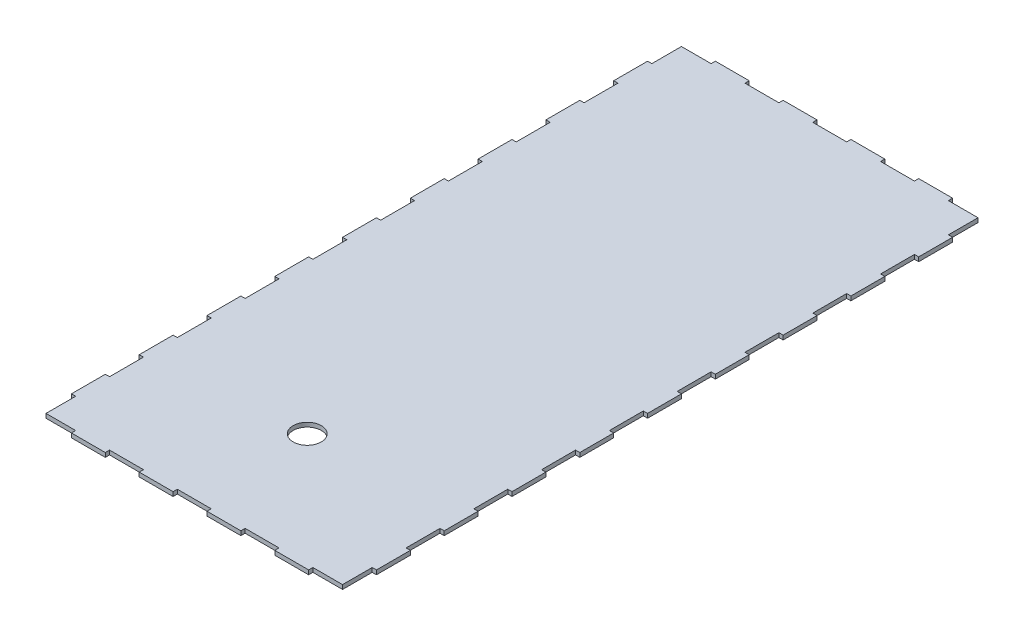
from build123d import *

# Parameters (mm, degrees)
SKETCH1_W           = 210
SKETCH1_H           = 450
SKETCH1_R           = 10
BOSS_EXTRUDE1_DEPTH = 3
SKETCH3_W           = 3
SKETCH3_H           = 24
BOSS_EXTRUDE3_DEPTH = 3
SKETCH2_W           = 24
SKETCH2_H           = 3
BOSS_EXTRUDE4_DEPTH = 3


with BuildPart() as part:
    # Sketch1 → Boss-Extrude1 (new body)
    with BuildSketch(Plane(origin=(0, 0, 0), x_dir=(1, 0, 0), z_dir=(0, 1, 0))):
        Rectangle(SKETCH1_W, SKETCH1_H)
        with Locations((0, -145)):
            Circle(SKETCH1_R, mode=Mode.SUBTRACT)
    extrude(amount=BOSS_EXTRUDE1_DEPTH)

    # Sketch3 → Boss-Extrude3 (add)
    with BuildSketch(Plane(origin=(0, 3, 0), x_dir=(1, 0, 0), z_dir=(0, 1, 0))):
        with Locations((-106.5, 192)):
            Rectangle(SKETCH3_W, SKETCH3_H)
        with Locations((106.5, 192)):
            Rectangle(SKETCH3_W, SKETCH3_H)
        with Locations((106.5, 144)):
            Rectangle(SKETCH3_W, SKETCH3_H)
        with Locations((106.5, 96)):
            Rectangle(SKETCH3_W, SKETCH3_H)
        with Locations((106.5, 48)):
            Rectangle(SKETCH3_W, SKETCH3_H)
        with Locations((106.5, 0)):
            Rectangle(SKETCH3_W, SKETCH3_H)
        with Locations((106.5, -48)):
            Rectangle(SKETCH3_W, SKETCH3_H)
        with Locations((106.5, -96)):
            Rectangle(SKETCH3_W, SKETCH3_H)
        with Locations((106.5, -144)):
            Rectangle(SKETCH3_W, SKETCH3_H)
        with Locations((106.5, -192)):
            Rectangle(SKETCH3_W, SKETCH3_H)
        with Locations((-106.5, 144)):
            Rectangle(SKETCH3_W, SKETCH3_H)
        with Locations((-106.5, 96)):
            Rectangle(SKETCH3_W, SKETCH3_H)
        with Locations((-106.5, 48)):
            Rectangle(SKETCH3_W, SKETCH3_H)
        with Locations((-106.5, 0)):
            Rectangle(SKETCH3_W, SKETCH3_H)
        with Locations((-106.5, -48)):
            Rectangle(SKETCH3_W, SKETCH3_H)
        with Locations((-106.5, -96)):
            Rectangle(SKETCH3_W, SKETCH3_H)
        with Locations((-106.5, -144)):
            Rectangle(SKETCH3_W, SKETCH3_H)
        with Locations((-106.5, -192)):
            Rectangle(SKETCH3_W, SKETCH3_H)
    extrude(amount=-BOSS_EXTRUDE3_DEPTH)

    # Sketch2 → Boss-Extrude4 (add)
    with BuildSketch(Plane(origin=(0, 3, 0), x_dir=(1, 0, 0), z_dir=(0, 1, 0))):
        with Locations((-72, 226.5)):
            Rectangle(SKETCH2_W, SKETCH2_H)
        with Locations((-24, 226.5)):
            Rectangle(SKETCH2_W, SKETCH2_H)
        with Locations((24, 226.5)):
            Rectangle(SKETCH2_W, SKETCH2_H)
        with Locations((72, 226.5)):
            Rectangle(SKETCH2_W, SKETCH2_H)
        with Locations((-71.999992639, -226.5)):
            Rectangle(SKETCH2_W, SKETCH2_H)
        with Locations((-23.999992639, -226.5)):
            Rectangle(SKETCH2_W, SKETCH2_H)
        with Locations((24.000007361, -226.5)):
            Rectangle(SKETCH2_W, SKETCH2_H)
        with Locations((72.000007361, -226.5)):
            Rectangle(SKETCH2_W, SKETCH2_H)
    extrude(amount=-BOSS_EXTRUDE4_DEPTH)


solid = part.part
